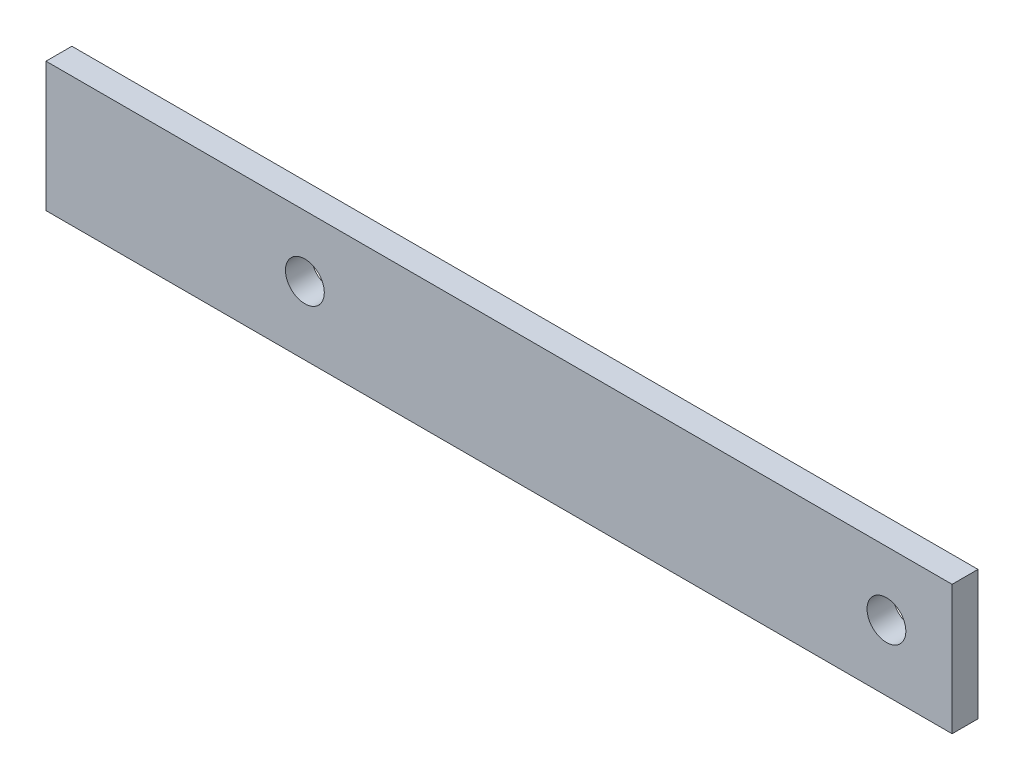
from build123d import *

# Parameters (mm, degrees)
SKETCH1_W           = 70
SKETCH1_H           = 10
BOSS_EXTRUDE1_DEPTH = 2
SKETCH2_R           = 1.5
CUT_EXTRUDE1_DEPTH  = 2
SKETCH3_R           = 1.5
CUT_EXTRUDE2_DEPTH  = 10


with BuildPart() as part:
    # Sketch1 → Boss-Extrude1 (new body)
    with BuildSketch(Plane.XY):
        with Locations((-35, -5)):
            Rectangle(SKETCH1_W, SKETCH1_H)
    extrude(amount=BOSS_EXTRUDE1_DEPTH)

    # Sketch2 → Cut-Extrude1 (cut)
    with BuildSketch(Plane.XY.offset(2)):
        with Locations((-5.07364211, -4.928592782)):
            Circle(SKETCH2_R)
    extrude(amount=-CUT_EXTRUDE1_DEPTH, mode=Mode.SUBTRACT)

    # Sketch3 → Cut-Extrude2 (cut)
    with BuildSketch(Plane.XY.offset(2)):
        with Locations((-50, -4.733233439)):
            Circle(SKETCH3_R)
    extrude(amount=-CUT_EXTRUDE2_DEPTH, mode=Mode.SUBTRACT)


solid = part.part
